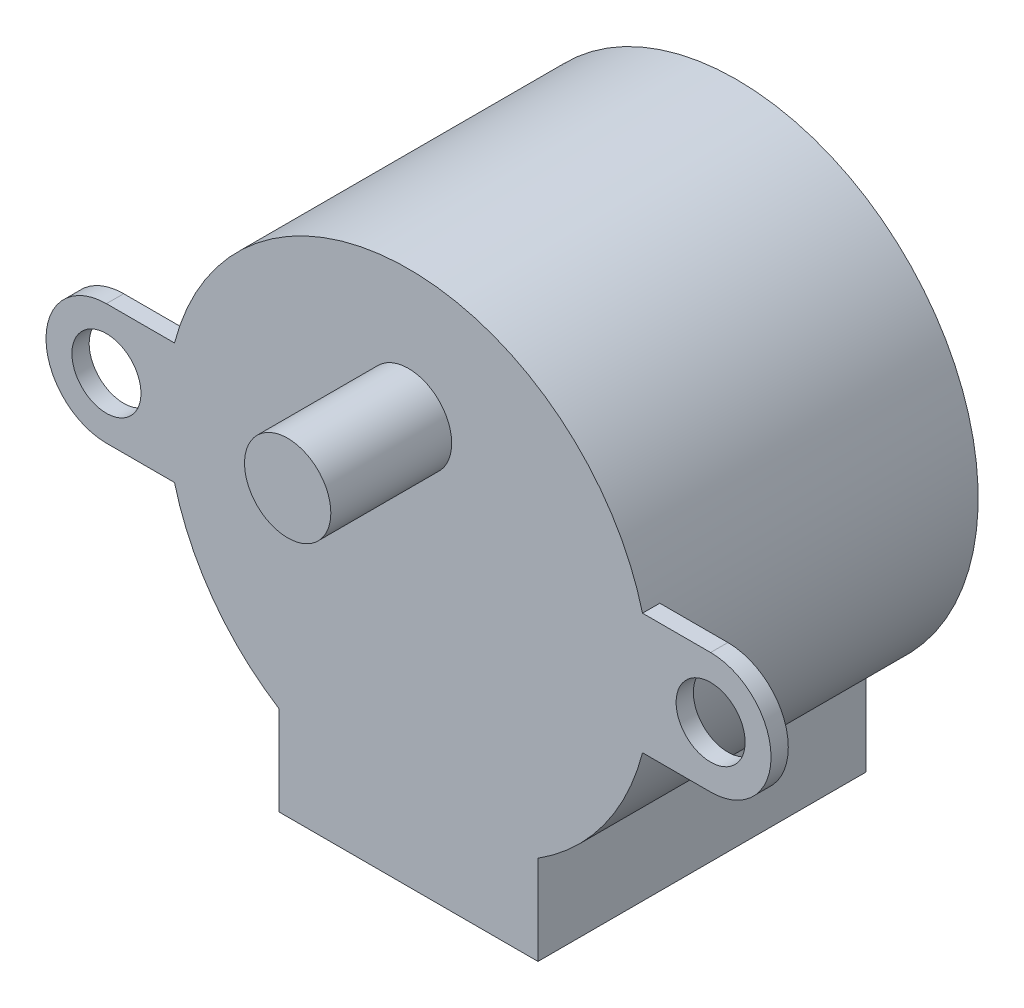
from build123d import *

# Parameters (mm, degrees)
ESBO_O1_R                = 2
RESSALTO_EXTRUS_O1_DEPTH = 19
CORTE_EXTRUS_O1_DEPTH    = 18
ESBO_O3_R                = 2.5
RESSALTO_EXTRUS_O2_DEPTH = 7


with BuildPart() as part:
    # Esboço1 → Ressalto-extrusão1 (new body)
    with BuildSketch(Plane.XY):
        with BuildLine():
            Line((17.5, 3.5), (13.555441712, 3.5))
            ThreePointArc((13.555441712, 3.5), (0, 14), (-13.555441712, 3.5))
            Line((-13.555441712, 3.5), (-17.5, 3.5))
            ThreePointArc((-17.5, 3.5), (-21, 0), (-17.5, -3.5))
            Line((-17.5, -3.5), (-13.555441712, -3.5))
            ThreePointArc((-13.555441712, -3.5), (-11.320120282, -8.237407166), (-7.5, -11.821590418))
            Line((-7.5, -11.821590418), (-7.5, -14))
            Line((-7.5, -14), (-7.5, -17))
            Line((-7.5, -17), (7.5, -17))
            Line((7.5, -17), (7.5, -14))
            Line((7.5, -14), (7.5, -11.821590418))
            ThreePointArc((7.5, -11.821590418), (11.320120282, -8.237407166), (13.555441712, -3.5))
            Line((13.555441712, -3.5), (17.5, -3.5))
            ThreePointArc((17.5, -3.5), (21, 0), (17.5, 3.5))
        make_face()
        with Locations((17.5, 0)):
            Circle(ESBO_O1_R, mode=Mode.SUBTRACT)
        with Locations((-17.5, 0)):
            Circle(ESBO_O1_R, mode=Mode.SUBTRACT)
    extrude(amount=RESSALTO_EXTRUS_O1_DEPTH)

    # Esboço2 → Corte-extrusão1 (cut)
    with BuildSketch(Plane(origin=(0, 0, 0), x_dir=(-1, 0, 0), z_dir=(0, 0, -1))):
        with BuildLine():
            Line((13.555441712, 3.5), (23.80699558, 3.5))
            Line((23.80699558, 3.5), (23.80699558, -3.5))
            Line((23.80699558, -3.5), (13.555441712, -3.5))
            ThreePointArc((13.555441712, -3.5), (14, 0), (13.555441712, 3.5))
        make_face()
        with BuildLine():
            Line((-13.555441712, 3.5), (-24.760546325, 3.5))
            Line((-24.760546325, 3.5), (-24.760546325, -3.5))
            Line((-24.760546325, -3.5), (-13.555441712, -3.5))
            ThreePointArc((-13.555441712, -3.5), (-14, 0), (-13.555441712, 3.5))
        make_face()
    extrude(amount=-CORTE_EXTRUS_O1_DEPTH, mode=Mode.SUBTRACT)

    # Esboço3 → Ressalto-extrusão2 (add)
    with BuildSketch(Plane.XY.offset(19)):
        with Locations((0, 6.5)):
            Circle(ESBO_O3_R)
    extrude(amount=RESSALTO_EXTRUS_O2_DEPTH)


solid = part.part
